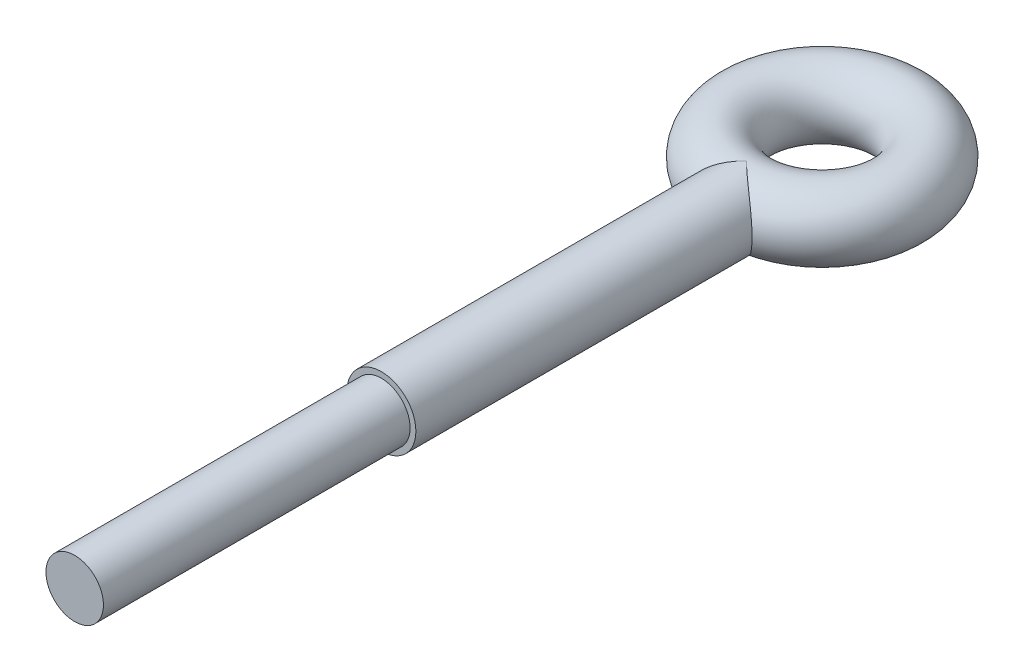
from build123d import *

# Parameters (mm, degrees)
SKETCH_1_R      = 1.8
EXTRUDE_1_REACH = 30.75
SKETCH_2_R      = 1.8
SKETCH_3_R      = 1.5
EXTRUDE_2_DEPTH = 16


with BuildPart() as part:
    # 草图1 → 旋转1 (revolve)
    with BuildSketch(Plane.XY):
        with Locations((-3.95, 0)):
            Circle(SKETCH_1_R)
    revolve(axis=Axis((0, 9.659818304, 0), (0, -1, 0)))

    # 草图2 → 凸台-拉伸1 (add, up to next)
    with BuildSketch(Plane.XY.offset(23), mode=Mode.PRIVATE) as extrude_1_sk1:
        Circle(SKETCH_2_R)
    extrude_1_tool1 = extrude(extrude_1_sk1.sketch, amount=-EXTRUDE_1_REACH, mode=Mode.PRIVATE) - part.part
    add(extrude_1_tool1.solids().sort_by_distance((0, 0, 23))[0])

    # 草图3 → 凸台-拉伸2 (add)
    with BuildSketch(Plane.XY.offset(23)):
        Circle(SKETCH_3_R)
    extrude(amount=EXTRUDE_2_DEPTH)


solid = part.part
